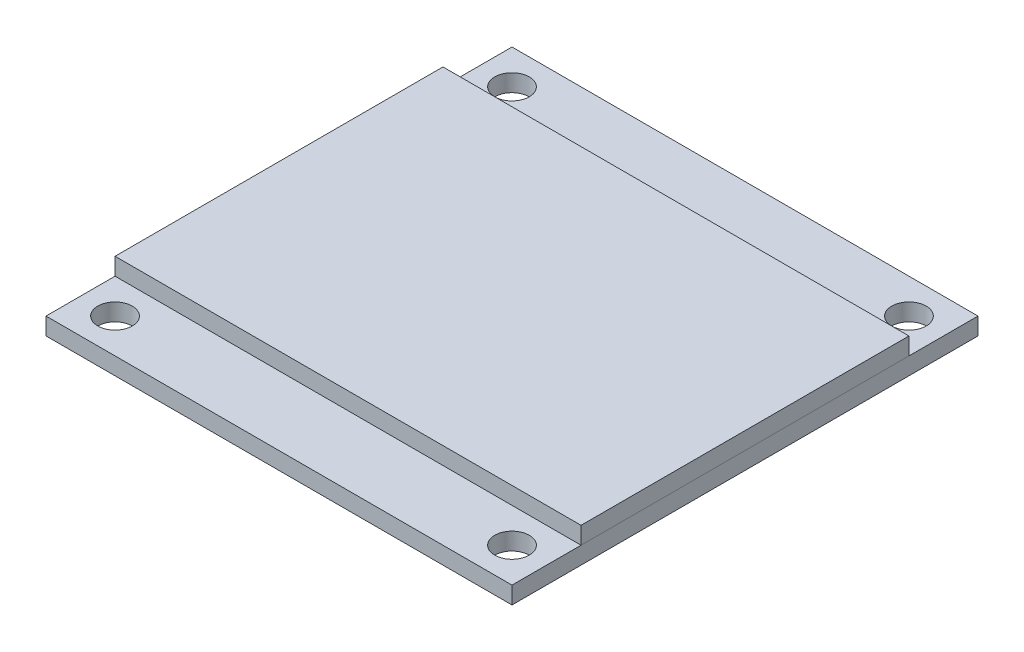
from build123d import *

# Parameters (mm, degrees)
SKETCH1_W           = 27
SKETCH1_H           = 27
SKETCH1_R           = 1
BOSS_EXTRUDE1_DEPTH = 1
SKETCH2_W           = 27
SKETCH2_H           = 19
BOSS_EXTRUDE2_DEPTH = 1


with BuildPart() as part:
    # Sketch1 → Boss-Extrude1 (new body)
    with BuildSketch(Plane(origin=(0, 0, 0), x_dir=(1, 0, 0), z_dir=(0, 1, 0))):
        Rectangle(SKETCH1_W, SKETCH1_H)
        with Locations((-11.5, 11.5)):
            Circle(SKETCH1_R, mode=Mode.SUBTRACT)
        with Locations((11.5, 11.5)):
            Circle(SKETCH1_R, mode=Mode.SUBTRACT)
        with Locations((11.5, -11.5)):
            Circle(SKETCH1_R, mode=Mode.SUBTRACT)
        with Locations((-11.5, -11.5)):
            Circle(SKETCH1_R, mode=Mode.SUBTRACT)
    extrude(amount=BOSS_EXTRUDE1_DEPTH)


with BuildPart() as body_2:
    # Sketch2 → Boss-Extrude2 (new body)
    with BuildSketch(Plane(origin=(0, 1, 0), x_dir=(1, 0, 0), z_dir=(0, 1, 0))):
        Rectangle(SKETCH2_W, SKETCH2_H)
    extrude(amount=BOSS_EXTRUDE2_DEPTH)


solid = Compound([part.part, body_2.part])
